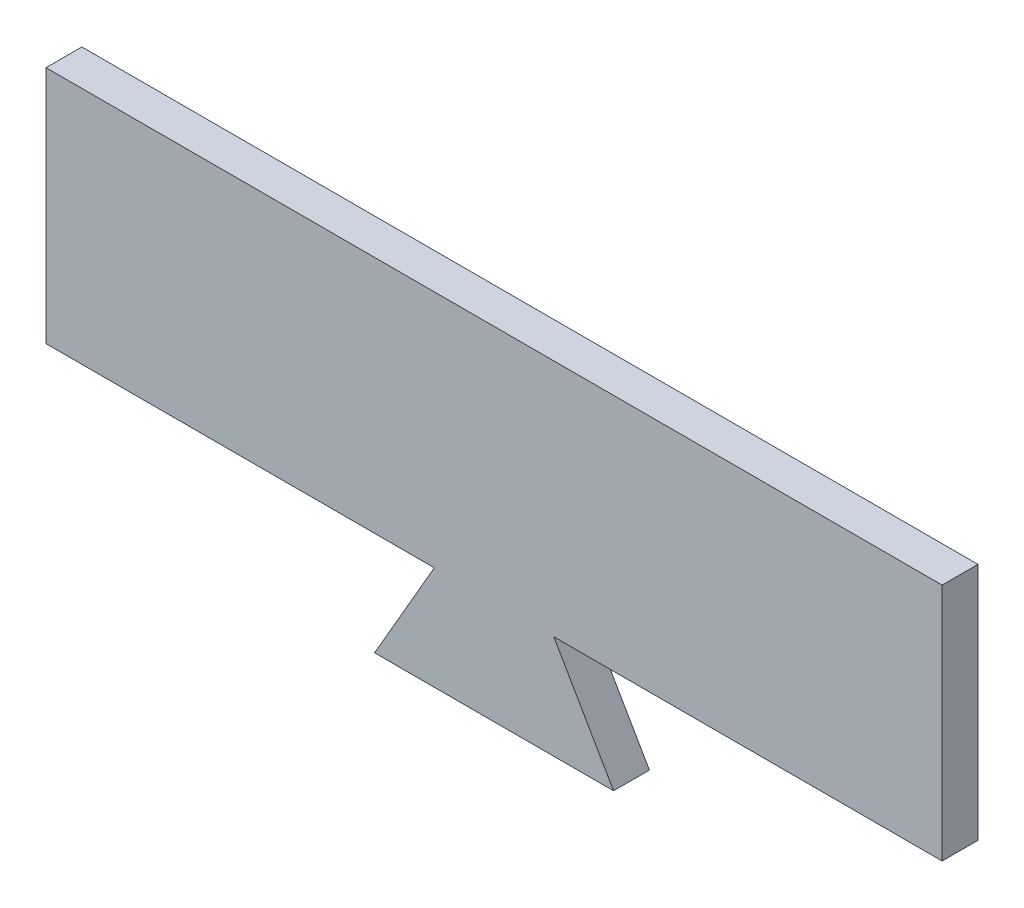
from build123d import *

# Parameters (mm, degrees)
BOSS_EXTRU_1_DEPTH = 6


with BuildPart() as part:
    # Esquisse1 → Boss.-Extru.1 (new body)
    with BuildSketch(Plane.XY):
        Polygon((-80.03906112, 74.201802975), (69.96093888, 74.201802975), (69.96093888, 34.201802975), (4.96093888, 34.201802975), (14.96093888, 16.8812949), (-25.03906112, 16.8812949), (-15.03906112, 34.201802975), (-80.03906112, 34.201802975), align=None)
    extrude(amount=BOSS_EXTRU_1_DEPTH)


solid = part.part
